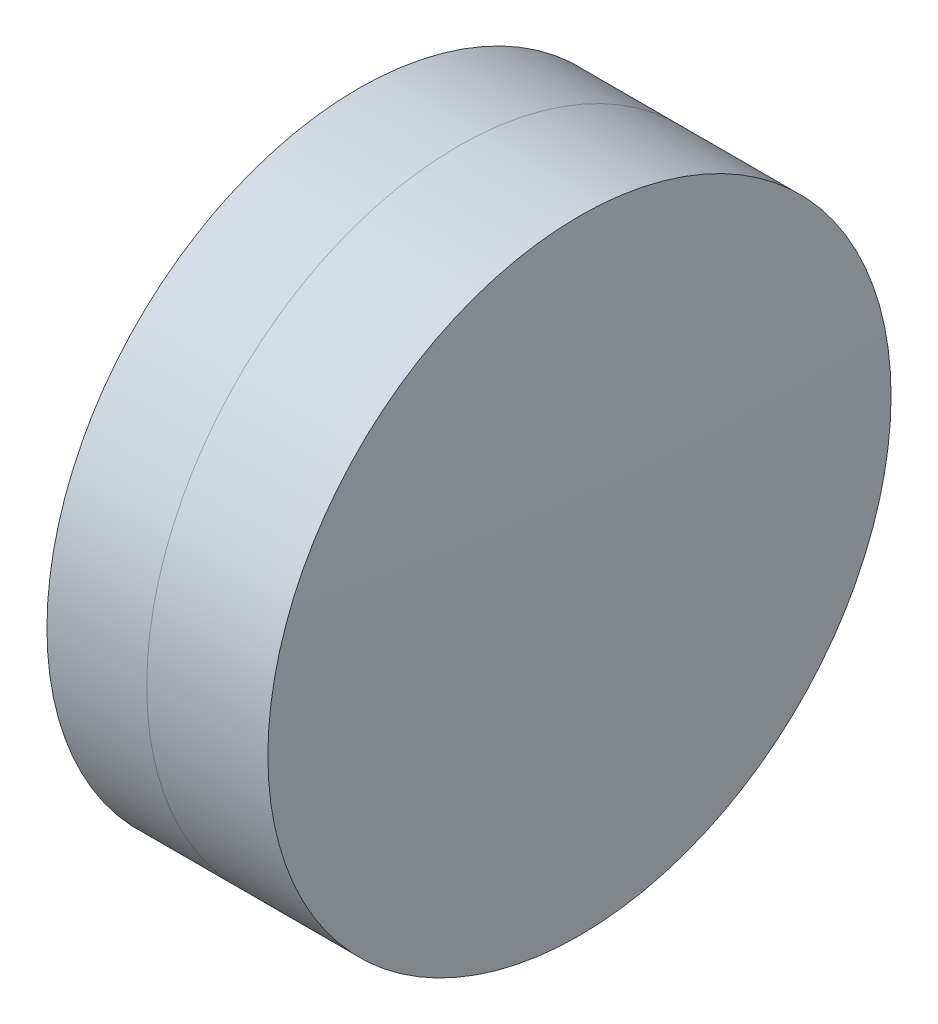
from build123d import *


with BuildPart() as part:
    # 草图1 one side → 旋转1 (revolve)
    with BuildSketch(Plane(origin=(0, 0, 0), x_dir=(1, 0, 0), z_dir=(0, 1, 0)), mode=Mode.PRIVATE) as revolve_1_sk:
        with BuildLine():
            ThreePointArc((6.957592116, 5), (6.716817238, 2.505151345), (6.636448771, 0))
            Line((6.636448771, 0), (9.056448771, 0))
            ThreePointArc((9.056448771, 0), (8.931740357, 2.51235016), (8.558841193, 5))
            Line((8.558841193, 5), (6.957592116, 5))
        make_face()
    revolve(revolve_1_sk.sketch.rotate(Axis((-9.702612178, 0, 0), (1, 0, 0)), 180), axis=Axis((-9.702612178, 0, 0), (1, 0, 0)))  # turned: the seam where the file's is


with BuildPart() as body_2:
    # 草图2 one side → 旋转3 (revolve)
    with BuildSketch(Plane(origin=(0, 0, 0), x_dir=(1, 0, 0), z_dir=(0, 1, 0)), mode=Mode.PRIVATE) as revolve_3_sk:
        with BuildLine():
            Line((10.503171133, 5), (8.558841193, 5))
            ThreePointArc((8.558841193, 5), (8.931740357, 2.51235016), (9.056448771, 0))
            Line((9.056448771, 0), (10.656448771, 0))
            ThreePointArc((10.656448771, 0), (10.618120363, 2.501174426), (10.503171133, 5))
        make_face()
    revolve(revolve_3_sk.sketch.rotate(Axis((-0.551919993, 0, 0), (1, 0, 0)), 180), axis=Axis((-0.551919993, 0, 0), (1, 0, 0)))  # turned: the seam where the file's is


solid = Compound([part.part, body_2.part])
